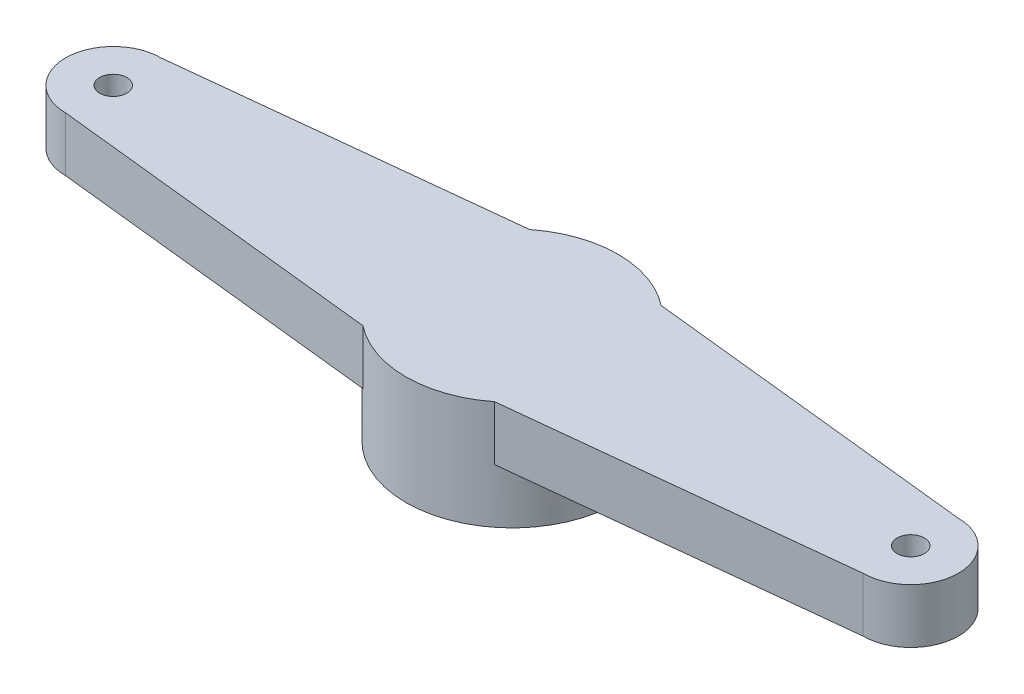
from build123d import *

# Parameters (mm, degrees)
SKETCH3_R                = 3.9
BOSS_EXTRUDE1_DEPTH      = 2
BOSS_EXTRUDE1_DEPTH_BACK = 2
SKETCH5_R                = 0.5
BOSS_EXTRUDE4_DEPTH      = 2
SKETCH4_R                = 2.25
CUT_EXTRUDE1_DEPTH       = 3


with BuildPart() as part:
    # Sketch3 → Boss-Extrude1 (new body, two sides)
    with BuildSketch(Plane(origin=(0, 0, 0), x_dir=(1, 0, 0), z_dir=(0, 1, 0))) as boss_extrude1_sk:
        with Locations((-5.706641347, -37.429153992)):
            Circle(SKETCH3_R)
    extrude(amount=BOSS_EXTRUDE1_DEPTH)
    extrude(boss_extrude1_sk.sketch, amount=-BOSS_EXTRUDE1_DEPTH_BACK)

    # Sketch5 → Boss-Extrude4 (add)
    with BuildSketch(Plane(origin=(0, 0, 0), x_dir=(1, 0, 0), z_dir=(0, 1, 0))):
        with BuildLine():
            Line((8.943358653, -35.679153992), (-5.706641347, -34.108983126))
            Line((-5.706641347, -34.108983126), (-20.356641347, -35.679153992))
            ThreePointArc((-20.356641347, -35.679153992), (-22.106641347, -37.429153992), (-20.356641347, -39.179153992))
            Line((-20.356641347, -39.179153992), (-5.706641347, -40.749324858))
            Line((-5.706641347, -40.749324858), (8.943358653, -39.179153992))
            ThreePointArc((8.943358653, -39.179153992), (10.693358653, -37.429153992), (8.943358653, -35.679153992))
        make_face()
        with Locations((8.943358653, -37.429153992)):
            Circle(SKETCH5_R, mode=Mode.SUBTRACT)
        with Locations((-20.356641347, -37.429153992)):
            Circle(SKETCH5_R, mode=Mode.SUBTRACT)
    extrude(amount=BOSS_EXTRUDE4_DEPTH)

    # Sketch4 → Cut-Extrude1 (cut, through all)
    with BuildSketch(Plane(origin=(0, 0, 0), x_dir=(1, 0, 0), z_dir=(0, 1, 0))):
        with Locations((-5.706641347, -37.429153992)):
            Circle(SKETCH4_R)
    extrude(amount=-CUT_EXTRUDE1_DEPTH, mode=Mode.SUBTRACT)


solid = part.part
